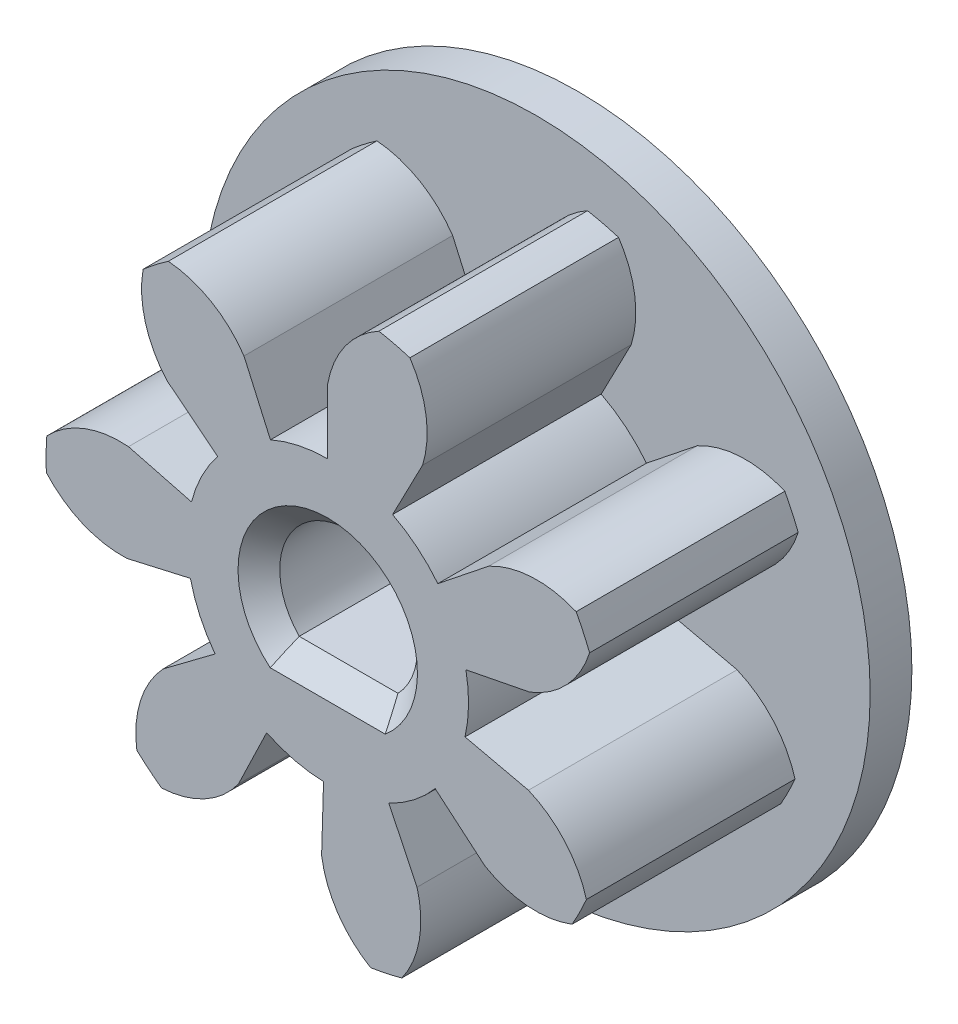
from build123d import *

# Parameters (mm, degrees)
SKETCH2_R                   = 6.75
GEAR_OUTSIDE_DIAMETER_DEPTH = 5
GEAR_TOOTH_CUT_DEPTH        = 6
GEAR_TEETH_COUNT            = 7
SKETCH3_R                   = 3.375
GEAR_DEDENDUM_CIRCLE_DEPTH  = 5
SKETCH5_R                   = 8
BOSS_EXTRUDE1_DEPTH         = 1
CUT_EXTRUDE1_DEPTH          = 7
CHAMFER2_SIZE               = 0.5


with BuildPart() as part:
    # Sketch2 → gear outside diameter (new body)
    with BuildSketch(Plane.XY):
        Circle(SKETCH2_R)
    extrude(amount=GEAR_OUTSIDE_DIAMETER_DEPTH)

    # Sketch1 → gear tooth cut (cut, through all)
    with BuildSketch(Plane.XY):
        with BuildLine():
            Line((0, 4.933386259), (0, 3.375))
            ThreePointArc((0, 3.375), (-0.701885443, 3.301209146), (-1.373078899, 3.083063304))
            Line((-1.373078899, 3.083063304), (-2.007089948, 4.506649523))
            ThreePointArc((-2.007089948, 4.506649523), (-2.793182164, 5.242332608), (-3.820403893, 5.564801352))
            ThreePointArc((-3.820403893, 5.564801352), (-1.403770885, 6.602418292), (1.225966143, 6.637733575))
            ThreePointArc((1.225966143, 6.637733575), (0.41879145, 5.925245269), (0, 4.933386259))
        make_face()
    gear_tooth_cut = extrude(amount=GEAR_TOOTH_CUT_DEPTH, mode=Mode.SUBTRACT)

    # gear teeth: gear tooth cut ×7 about axis
    gear_teeth_axis = Axis((0, 0, 0), (0, 0, 1))
    for i in range(1, GEAR_TEETH_COUNT):
        add(gear_tooth_cut.rotate(gear_teeth_axis, i * 360 / GEAR_TEETH_COUNT), mode=Mode.SUBTRACT)

    # Sketch3 → gear dedendum circle (add)
    with BuildSketch(Plane.XY):
        Circle(SKETCH3_R)
    extrude(amount=GEAR_DEDENDUM_CIRCLE_DEPTH)

    # Sketch5 → Boss-Extrude1 (add)
    with BuildSketch(Plane(origin=(0, 0, 0), x_dir=(-1, 0, 0), z_dir=(0, 0, -1))):
        Circle(SKETCH5_R)
    extrude(amount=BOSS_EXTRUDE1_DEPTH)

    # Sketch4 → Cut-Extrude1 (cut, through all)
    with BuildSketch(Plane.XY.offset(5)):
        with BuildLine():
            Line((-1.183215957, -1.15), (1.183215957, -1.15))
            ThreePointArc((1.183215957, -1.15), (0, 1.65), (-1.183215957, -1.15))
        make_face()
    extrude(amount=-CUT_EXTRUDE1_DEPTH, mode=Mode.SUBTRACT)

    # Chamfer2
    chamfer2_edges = [part.edges().sort_by_distance(p)[0] for p in [
        (0, 1.65, -1),
        (0, -1.15, -1),
        (0, 1.65, 5),
        (0, -1.15, 5),
    ]]
    chamfer(chamfer2_edges, length=CHAMFER2_SIZE)


solid = part.part
